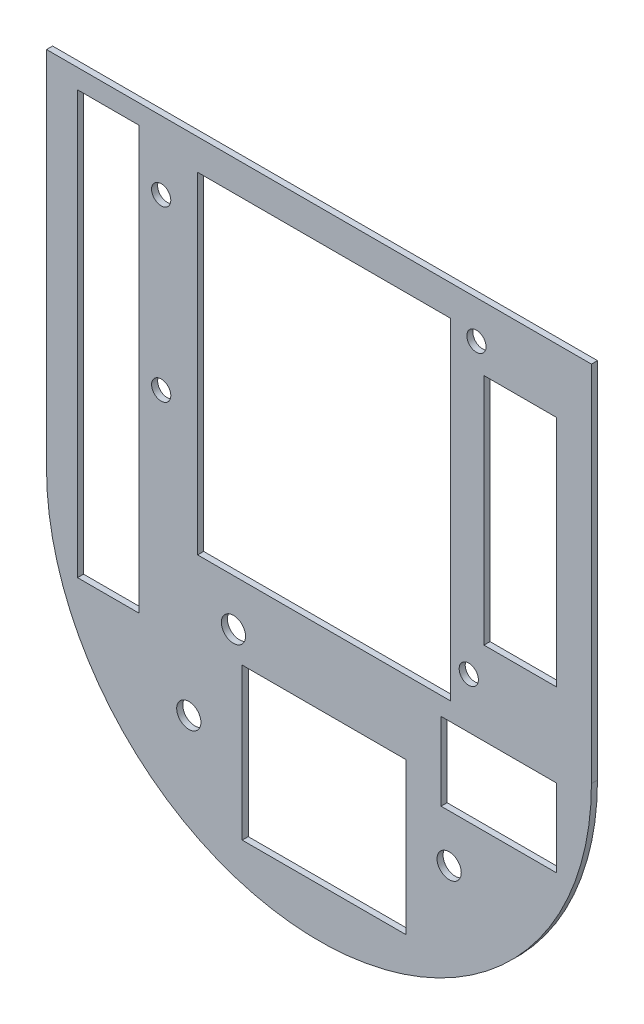
from build123d import *

# Parameters (mm, degrees)
SKETCH1_R           = 2
SKETCH1_R_2         = 1.5875
BOSS_EXTRUDE1_DEPTH = 1
SKETCH2_W           = 41.754758497
SKETCH2_H           = 54.729261875
SKETCH2_W_2         = 10.192494114
SKETCH2_H_2         = 69.784905138
SKETCH2_W_3         = 27.032266999
SKETCH2_H_3         = 25.038083368
SKETCH2_W_4         = 11.965101787
SKETCH2_H_4         = 38.554216868
SKETCH2_W_5         = 19.055532475
SKETCH2_H_5         = 12.851405623
CUT_EXTRUDE1_DEPTH  = 2


with BuildPart() as part:
    # Sketch1 → Boss-Extrude1 (new body)
    with BuildSketch(Plane.XY):
        with BuildLine():
            Line((61.109996011, 41.935724429), (61.109996011, -18.064275571))
            ThreePointArc((61.109996011, -18.064275571), (16.109996011, -63.064275571), (-28.890003989, -18.064275571))
            Line((-28.890003989, -18.064275571), (-28.890003989, 41.935724429))
            Line((-28.890003989, 41.935724429), (61.109996011, 41.935724429))
        make_face()
        with Locations((37.609996011, -41.564275571)):
            Circle(SKETCH1_R, mode=Mode.SUBTRACT)
        with Locations((-5.390003989, -41.564275571)):
            Circle(SKETCH1_R, mode=Mode.SUBTRACT)
        with Locations((1.984996011, -25.564275571)):
            Circle(SKETCH1_R, mode=Mode.SUBTRACT)
        with Locations((-9.950003989, 2.691836123)):
            Circle(SKETCH1_R_2, mode=Mode.SUBTRACT)
        with Locations((40.849996011, -12.548163877)):
            Circle(SKETCH1_R_2, mode=Mode.SUBTRACT)
        with Locations((42.119996011, 35.711836123)):
            Circle(SKETCH1_R_2, mode=Mode.SUBTRACT)
        with Locations((-9.950003989, 30.631836123)):
            Circle(SKETCH1_R_2, mode=Mode.SUBTRACT)
    extrude(amount=BOSS_EXTRUDE1_DEPTH)

    # Sketch2 → Cut-Extrude1 (cut, through all)
    with BuildSketch(Plane.XY.offset(1)):
        with Locations((16.947060745, 9.488348719)):
            Rectangle(SKETCH2_W, SKETCH2_H)
        with Locations((-18.677429553, 3.843922739)):
            Rectangle(SKETCH2_W_2, SKETCH2_H_2)
        with Locations((16.947060745, -42.471213668)):
            Rectangle(SKETCH2_W_3, SKETCH2_H_3)
        with Locations((49.346389863, 12.147260227)):
            Rectangle(SKETCH2_W_4, SKETCH2_H_4)
        with Locations((45.801174519, -27.293260477)):
            Rectangle(SKETCH2_W_5, SKETCH2_H_5)
    extrude(amount=-CUT_EXTRUDE1_DEPTH, mode=Mode.SUBTRACT)


solid = part.part
